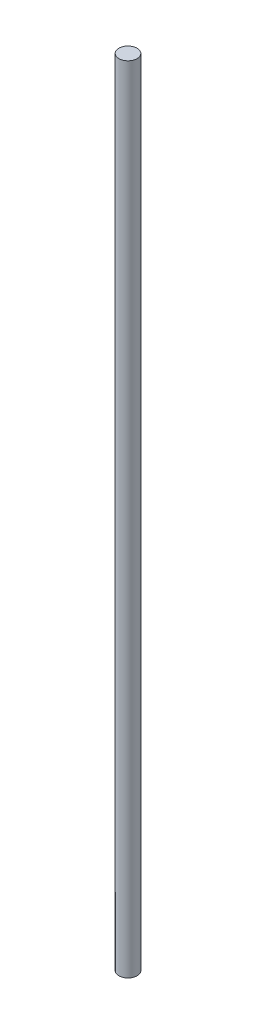
from build123d import *

# Parameters (mm, degrees)
SKETCH_1_R      = 4
EXTRUDE_1_DEPTH = 350


with BuildPart() as part:
    # 草圖1 → 填料-伸長1 (new body)
    with BuildSketch(Plane(origin=(0, 0, 0), x_dir=(1, 0, 0), z_dir=(0, 1, 0))):
        Circle(SKETCH_1_R)
    extrude(amount=EXTRUDE_1_DEPTH)


solid = part.part
